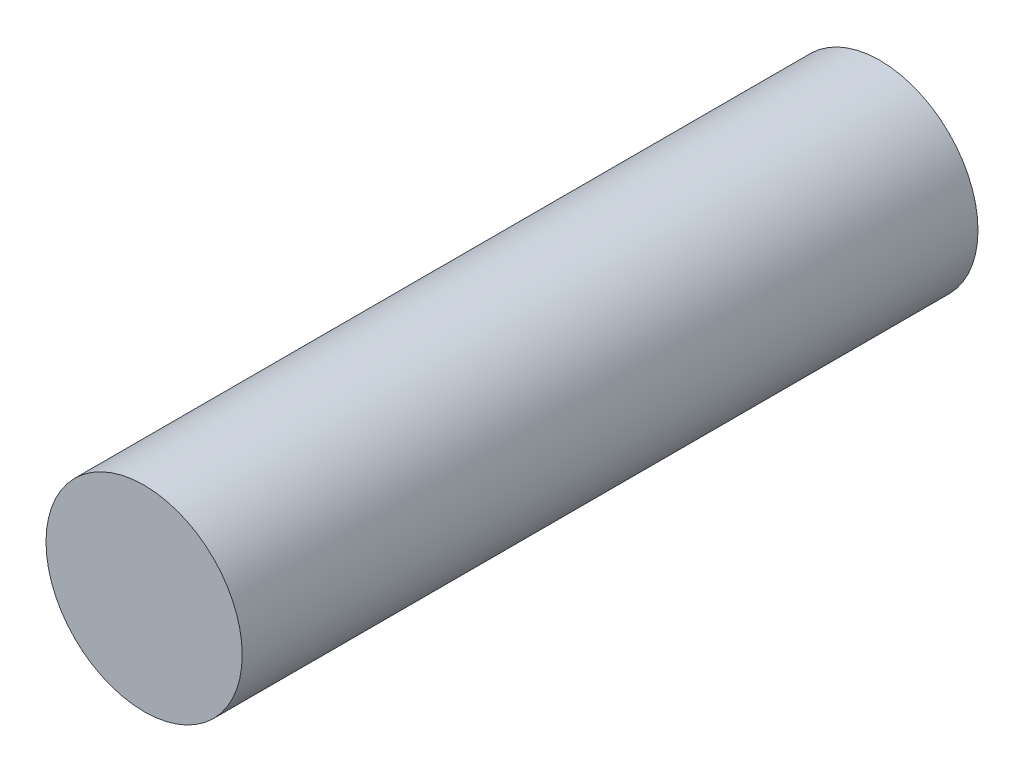
from build123d import *

# Parameters (mm, degrees)
ESQUISSE1_R        = 4
BOSS_EXTRU_1_DEPTH = 30


with BuildPart() as part:
    # Esquisse1 → Boss.-Extru.1 (new body)
    with BuildSketch(Plane.XY):
        Circle(ESQUISSE1_R)
    extrude(amount=BOSS_EXTRU_1_DEPTH)


solid = part.part
